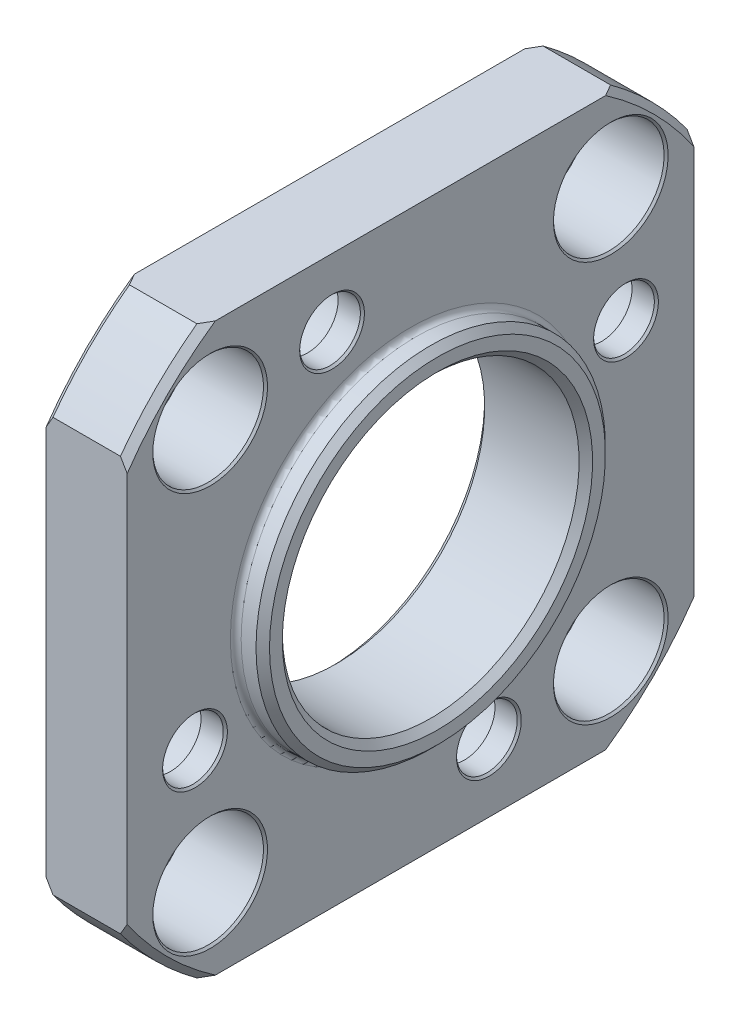
from build123d import *

# Parameters (mm, degrees)
CUT_EXTRUDE_1_REACH              = 10
HOLE_WIZARD_M41_AT_2_COUNT       = 2
HOLE_WIZARD_M41_AT_2_PITCH       = 24.04163056
HOLE_WIZARD_M41_AT_3_COUNT       = 2
HOLE_WIZARD_M41_AT_3_PITCH       = 34
HOLE_WIZARD_M41_AT_4_COUNT       = 2
HOLE_WIZARD_M41_AT_4_PITCH       = 24.04163056
HOLE_WIZARD_8_2_8_2_1_AT_2_COUNT = 2
HOLE_WIZARD_8_2_8_2_1_AT_2_PITCH = 29.69848481
HOLE_WIZARD_8_2_8_2_1_AT_3_COUNT = 2
HOLE_WIZARD_8_2_8_2_1_AT_3_PITCH = 42
HOLE_WIZARD_8_2_8_2_1_AT_4_COUNT = 2
HOLE_WIZARD_8_2_8_2_1_AT_4_PITCH = 29.69848481


with BuildPart() as part:
    # Эскиз1 → Повернуть1 (revolve)
    with BuildSketch(Plane.XY):
        with BuildLine():
            Line((7.5, 11), (0.5, 11))
            Line((0.5, 11), (0, 11.5))
            Line((0, 11.5), (0, 25.5))
            Line((0, 25.5), (0.5, 26))
            Line((0.5, 26), (5.5, 26))
            Line((5.5, 26), (6, 25.5))
            Line((6, 25.5), (6, 13.35))
            ThreePointArc((6, 13.35), (6.117157288, 13.067157288), (6.4, 12.95))
            Line((6.4, 12.95), (7.5, 12.95))
            Line((7.5, 12.95), (8, 12.45))
            Line((8, 12.45), (8, 11.5))
            Line((8, 11.5), (7.5, 11))
        make_face()
    revolve(axis=Axis((0, 0, 0), (1, 0, 0)))

    # Эскиз2 → Вырез-Вытянуть1 (cut, up to next)
    with BuildSketch(Plane.ZY, mode=Mode.PRIVATE) as cut_extrude_1_sk1:
        with BuildLine():
            Line((-15.329709717, 21), (15.329709717, 21))
            ThreePointArc((15.329709717, 21), (0, 26), (-15.329709717, 21))
        make_face()
    cut_extrude_1_tool1 = extrude(cut_extrude_1_sk1.sketch, amount=-CUT_EXTRUDE_1_REACH, mode=Mode.PRIVATE) & part.part
    add(cut_extrude_1_tool1.solids().sort_by_distance((0, 23.017458, 0))[0], mode=Mode.SUBTRACT)
    # Эскиз2 → Вырез-Вытянуть1 (cut, up to next)
    with BuildSketch(Plane.ZY, mode=Mode.PRIVATE) as cut_extrude_1_sk2:
        with BuildLine():
            Line((21, 15.329709717), (21, -15.329709717))
            ThreePointArc((21, -15.329709717), (26, 0), (21, 15.329709717))
        make_face()
    cut_extrude_1_tool2 = extrude(cut_extrude_1_sk2.sketch, amount=-CUT_EXTRUDE_1_REACH, mode=Mode.PRIVATE) & part.part
    add(cut_extrude_1_tool2.solids().sort_by_distance((0, 0, 23.017458))[0], mode=Mode.SUBTRACT)
    # Эскиз2 → Вырез-Вытянуть1 (cut, up to next)
    with BuildSketch(Plane.ZY, mode=Mode.PRIVATE) as cut_extrude_1_sk3:
        with BuildLine():
            Line((15.329709717, -21), (-15.329709717, -21))
            ThreePointArc((-15.329709717, -21), (0, -26), (15.329709717, -21))
        make_face()
    cut_extrude_1_tool3 = extrude(cut_extrude_1_sk3.sketch, amount=-CUT_EXTRUDE_1_REACH, mode=Mode.PRIVATE) & part.part
    add(cut_extrude_1_tool3.solids().sort_by_distance((0, -23.017458, 0))[0], mode=Mode.SUBTRACT)
    # Эскиз2 → Вырез-Вытянуть1 (cut, up to next)
    with BuildSketch(Plane.ZY, mode=Mode.PRIVATE) as cut_extrude_1_sk4:
        with BuildLine():
            Line((-21, -15.329709717), (-21, 15.329709717))
            ThreePointArc((-21, 15.329709717), (-26, 0), (-21, -15.329709717))
        make_face()
    cut_extrude_1_tool4 = extrude(cut_extrude_1_sk4.sketch, amount=-CUT_EXTRUDE_1_REACH, mode=Mode.PRIVATE) & part.part
    add(cut_extrude_1_tool4.solids().sort_by_distance((0, 0, -23.017458))[0], mode=Mode.SUBTRACT)

    # Эскиз4 → Цековка для винта с внутренним шестигранником M41 (revolve, cut)
    with BuildSketch(Plane(origin=(0, 15.974774553, 5.814342437), x_dir=(0, 0, 1), z_dir=(0, 1, 0))):
        Polygon((0, 0), (0, 6), (2.4, 6), (2.25, 5.85), (2.25, 4.2), (3.7, 4.2), (3.7, 0.15), (3.85, 0), align=None)
    hole_wizard_m41 = revolve(axis=Axis((-6.35, 15.974774553, 5.814342437), (1, 0, 0)), mode=Mode.SUBTRACT)

    # Цековка для винта с внутренним шестигранником M41 at 2: Цековка для винта с внутренним шестигранником M41 ×2
    with Locations(*[Vector(0, -0.422618262, -0.906307787) * (i * HOLE_WIZARD_M41_AT_2_PITCH) for i in range(1, HOLE_WIZARD_M41_AT_2_COUNT)]):
        add(hole_wizard_m41, mode=Mode.SUBTRACT)

    # Цековка для винта с внутренним шестигранником M41 at 3: Цековка для винта с внутренним шестигранником M41 ×2
    with Locations(*[Vector(0, -0.939692621, -0.342020143) * (i * HOLE_WIZARD_M41_AT_3_PITCH) for i in range(1, HOLE_WIZARD_M41_AT_3_COUNT)]):
        add(hole_wizard_m41, mode=Mode.SUBTRACT)

    # Цековка для винта с внутренним шестигранником M41 at 4: Цековка для винта с внутренним шестигранником M41 ×2
    with Locations(*[Vector(0, -0.906307787, 0.422618262) * (i * HOLE_WIZARD_M41_AT_4_PITCH) for i in range(1, HOLE_WIZARD_M41_AT_4_COUNT)]):
        add(hole_wizard_m41, mode=Mode.SUBTRACT)

    # Эскиз6 → Диаметр отверстия Ø8.2 (8.2)1 (revolve, cut)
    with BuildSketch(Plane(origin=(0, 14.849242405, -14.849242405), x_dir=(0, 0, 1), z_dir=(0, 1, 0))):
        Polygon((0, 0), (0, 6), (4.25, 6), (4.1, 5.85), (4.1, 0.15), (4.25, 0), align=None)
    hole_wizard_8_2_8_2_1 = revolve(axis=Axis((-6.35, 14.849242405, -14.849242405), (1, 0, 0)), mode=Mode.SUBTRACT)

    # Диаметр отверстия Ø8.2 (8.2)1 at 2: Диаметр отверстия Ø8.2 (8.2)1 ×2
    with Locations(*[(0, 0, i * HOLE_WIZARD_8_2_8_2_1_AT_2_PITCH) for i in range(1, HOLE_WIZARD_8_2_8_2_1_AT_2_COUNT)]):
        add(hole_wizard_8_2_8_2_1, mode=Mode.SUBTRACT)

    # Диаметр отверстия Ø8.2 (8.2)1 at 3: Диаметр отверстия Ø8.2 (8.2)1 ×2
    with Locations(*[Vector(0, -0.707106781, 0.707106781) * (i * HOLE_WIZARD_8_2_8_2_1_AT_3_PITCH) for i in range(1, HOLE_WIZARD_8_2_8_2_1_AT_3_COUNT)]):
        add(hole_wizard_8_2_8_2_1, mode=Mode.SUBTRACT)

    # Диаметр отверстия Ø8.2 (8.2)1 at 4: Диаметр отверстия Ø8.2 (8.2)1 ×2
    with Locations(*[(0, -i * HOLE_WIZARD_8_2_8_2_1_AT_4_PITCH, 0) for i in range(1, HOLE_WIZARD_8_2_8_2_1_AT_4_COUNT)]):
        add(hole_wizard_8_2_8_2_1, mode=Mode.SUBTRACT)


solid = part.part
